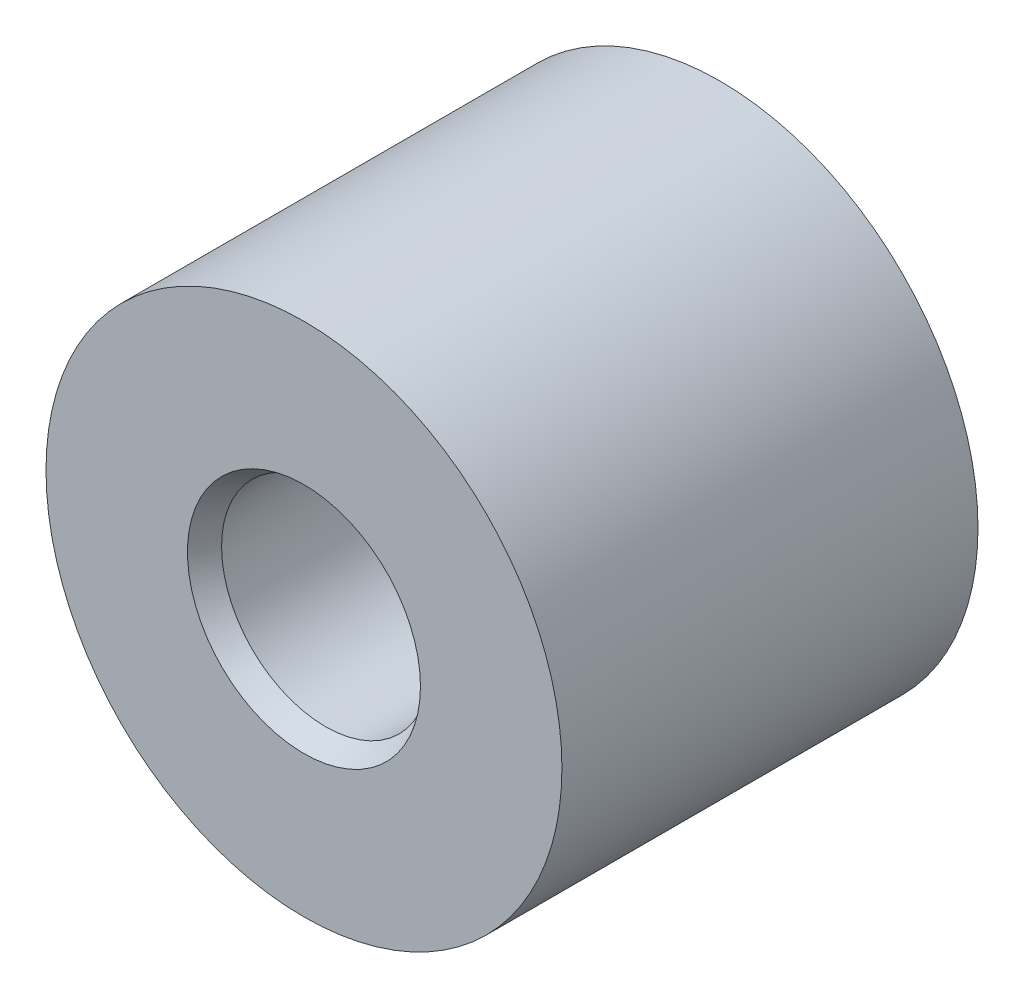
from build123d import *

# Parameters (mm, degrees)
SKETCH2_R                            = 3.1
BOSS_EXTRUDE1_DEPTH                  = 5
F_2_5_2_5_DIAMETER_HOLE1_D           = 2.5
F_2_5_2_5_DIAMETER_HOLE1_DEPTH       = 5
F_2_5_2_5_DIAMETER_HOLE1_CSINK_D     = 2.8
F_2_5_2_5_DIAMETER_HOLE1_CSINK_ANGLE = 60


with BuildPart() as part:
    # Sketch2 → Boss-Extrude1 (new body)
    with BuildSketch(Plane.XY):
        Circle(SKETCH2_R)
    extrude(amount=-BOSS_EXTRUDE1_DEPTH)

    # Ø2.5 (2.5) Diameter Hole1
    with Locations(Plane.XY):
        with Locations((0, 0)):
            CounterSinkHole(F_2_5_2_5_DIAMETER_HOLE1_D / 2, F_2_5_2_5_DIAMETER_HOLE1_CSINK_D / 2, depth=F_2_5_2_5_DIAMETER_HOLE1_DEPTH, counter_sink_angle=F_2_5_2_5_DIAMETER_HOLE1_CSINK_ANGLE)


solid = part.part
